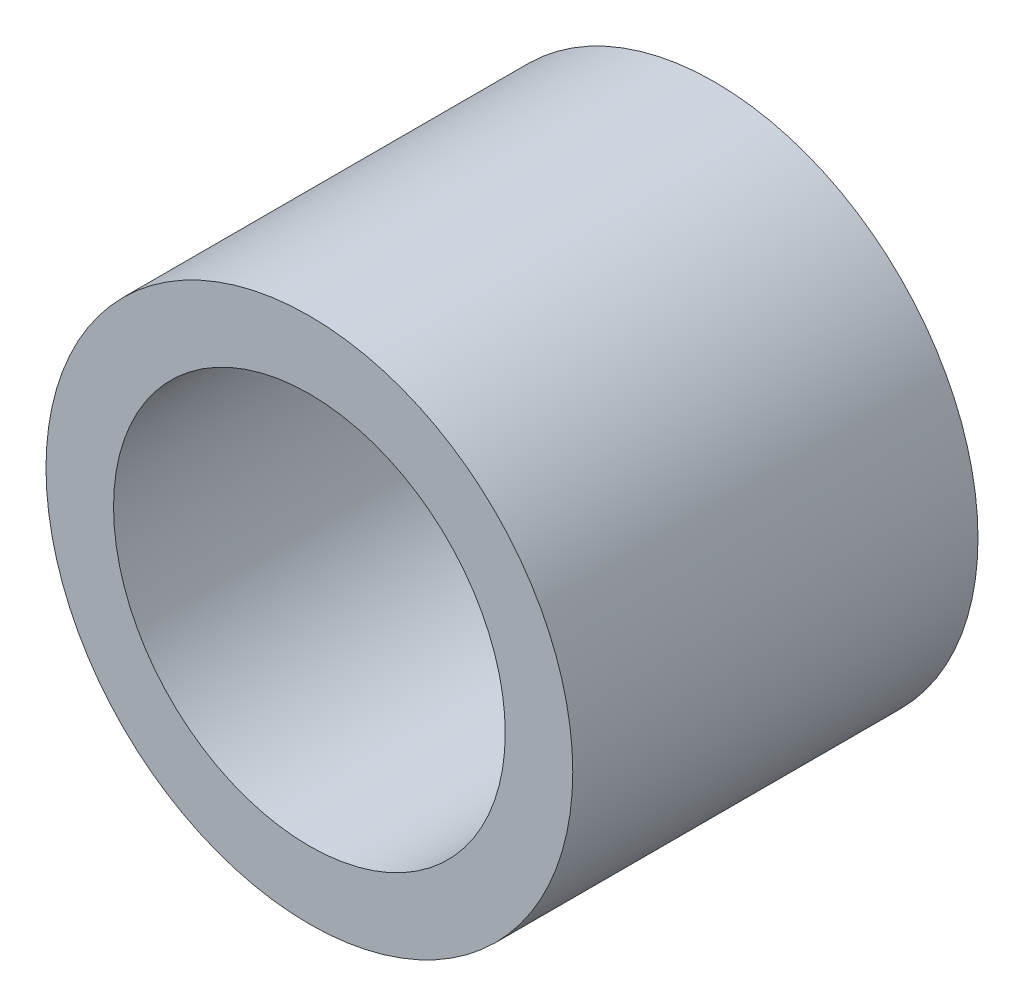
from build123d import *

# Parameters (mm, degrees)
SKETCH1_R           = 3.9
SKETCH1_R_2         = 2.9
BOSS_EXTRUDE1_DEPTH = 6


with BuildPart() as part:
    # Sketch1 → Boss-Extrude1 (new body)
    with BuildSketch(Plane.XY):
        Circle(SKETCH1_R)
        Circle(SKETCH1_R_2, mode=Mode.SUBTRACT)
    extrude(amount=BOSS_EXTRUDE1_DEPTH)


solid = part.part
